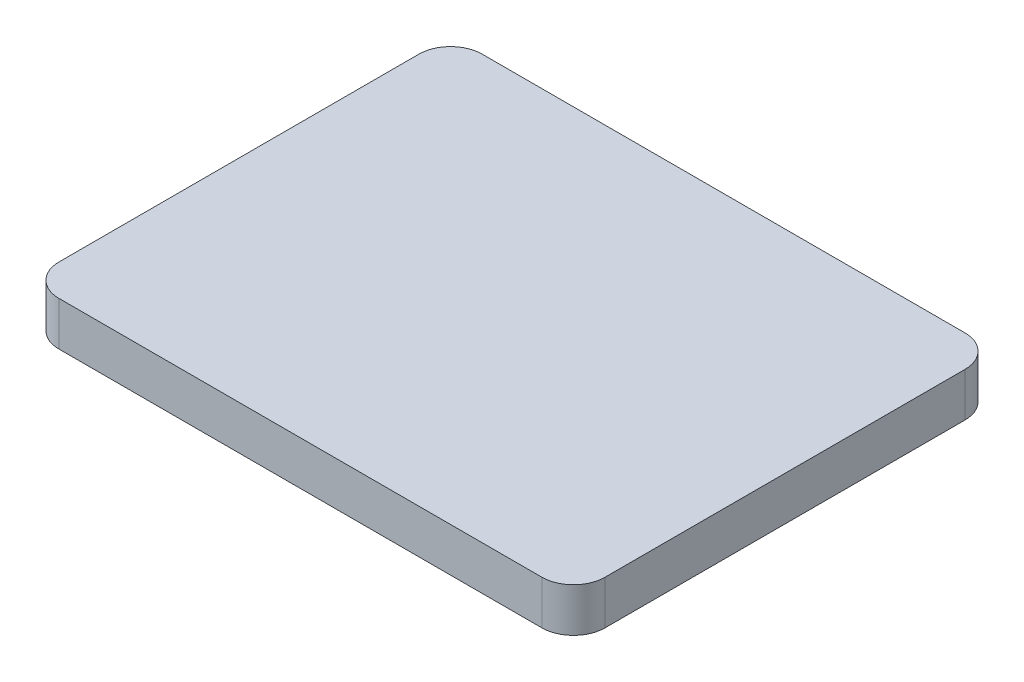
from build123d import *

# Parameters (mm, degrees)
SKETCH_2_W      = 29.5
SKETCH_2_H      = 22.5
LAYER_DEPTH     = 0.5
FILLET_1_R      = 1
EXTRUDE_1_DEPTH = 2.5


with BuildPart() as part:
    # 草图2 → layer (new body)
    with BuildSketch(Plane(origin=(0, 0, 0), x_dir=(1, 0, 0), z_dir=(0, 1, 0))):
        Rectangle(SKETCH_2_W, SKETCH_2_H)
    extrude(amount=LAYER_DEPTH)

    # 圆角1
    fillet_1_edges = [part.edges().sort_by_distance(p)[0] for p in [
        (14.75, 0.25, 11.25),
        (-14.75, 0.25, 11.25),
        (-14.75, 0.25, -11.25),
        (14.75, 0.25, -11.25),
    ]]
    fillet(fillet_1_edges, radius=FILLET_1_R)

    # 草图4 → 凸台-拉伸1 (add)
    with BuildSketch(Plane(origin=(0, 0.5, 0), x_dir=(1, 0, 0), z_dir=(0, 1, 0))):
        with BuildLine():
            Line((-13.75, -12.05), (13.75, -12.05))
            ThreePointArc((13.75, -12.05), (15.022792206, -11.522792206), (15.55, -10.25))
            Line((15.55, -10.25), (15.55, 10.25))
            ThreePointArc((15.55, 10.25), (15.022792206, 11.522792206), (13.75, 12.05))
            Line((13.75, 12.05), (-13.75, 12.05))
            ThreePointArc((-13.75, 12.05), (-15.022792206, 11.522792206), (-15.55, 10.25))
            Line((-15.55, 10.25), (-15.55, -10.25))
            ThreePointArc((-15.55, -10.25), (-15.022792206, -11.522792206), (-13.75, -12.05))
        make_face()
        with BuildLine():
            Line((-13.75, -11.25), (13.75, -11.25))
            ThreePointArc((13.75, -11.25), (14.457106781, -10.957106781), (14.75, -10.25))
            Line((14.75, -10.25), (14.75, 10.25))
            ThreePointArc((14.75, 10.25), (14.457106781, 10.957106781), (13.75, 11.25))
            Line((13.75, 11.25), (-13.75, 11.25))
            ThreePointArc((-13.75, 11.25), (-14.457106781, 10.957106781), (-14.75, 10.25))
            Line((-14.75, 10.25), (-14.75, -10.25))
            ThreePointArc((-14.75, -10.25), (-14.457106781, -10.957106781), (-13.75, -11.25))
        make_face(mode=Mode.SUBTRACT)
    extrude(amount=-EXTRUDE_1_DEPTH)


solid = part.part
